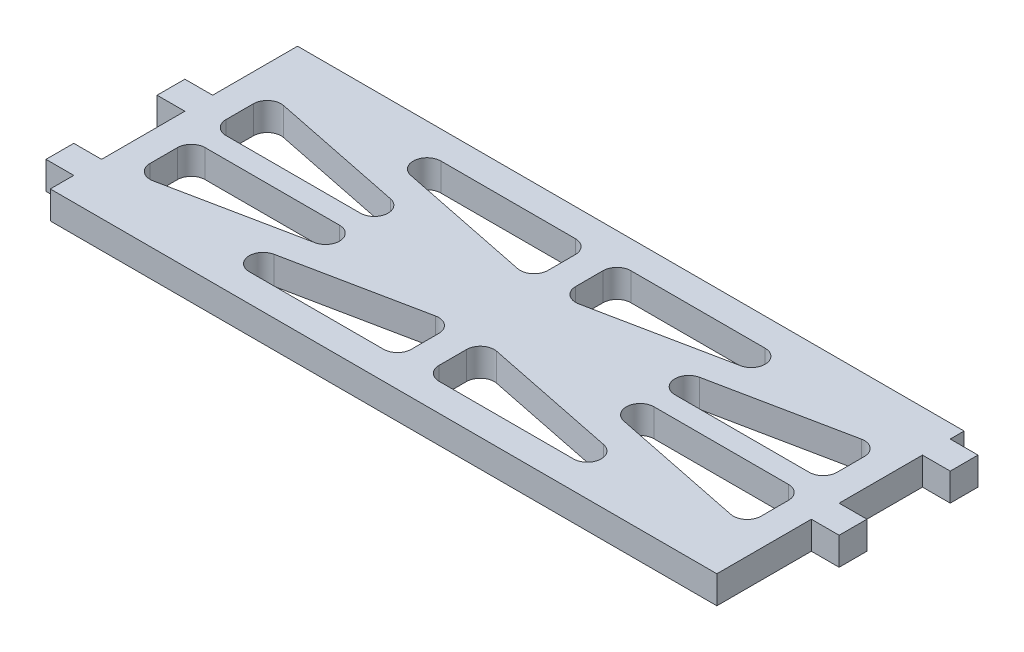
from build123d import *

# Parameters (mm, degrees)
BOSS_EXTRUDE1_DEPTH = 4
CUT_EXTRUDE1_DEPTH  = 10


with BuildPart() as part:
    # Sketch1 → Boss-Extrude1 (new body)
    with BuildSketch(Plane(origin=(0, 0, 0), x_dir=(1, 0, 0), z_dir=(0, 1, 0))):
        Polygon((-148, 18.23), (-148, 6), (-152, 6), (-152, 2), (-148, 2), (-148, -10), (-152, -10), (-152, -14), (-148, -14), (-148, -17.38), (-52, -17.38), (-52, -3.77), (-48, -3.77), (-48, 0.23), (-52, 0.23), (-52, 12.23), (-48, 12.23), (-48, 16.23), (-52, 16.23), (-52, 18.23), align=None)
    extrude(amount=-BOSS_EXTRUDE1_DEPTH)

    # Sketch2 → Cut-Extrude1 (cut)
    with BuildSketch(Plane(origin=(0, 0, 0), x_dir=(1, 0, 0), z_dir=(0, 1, 0))):
        with BuildLine():
            ThreePointArc((-144, 7.862318396), (-143.26536282, 9.411142768), (-141.601143065, 9.822143171))
            Line((-141.601143065, 9.822143171), (-122.254722174, 5.884824774))
            ThreePointArc((-122.254722174, 5.884824774), (-120.663648262, 3.724562414), (-122.653579109, 1.925))
            Line((-122.653579109, 1.925), (-142, 1.925))
            ThreePointArc((-142, 1.925), (-143.414213562, 2.510786438), (-144, 3.925))
            Line((-144, 3.925), (-144, 7.862318396))
        make_face()
        with BuildLine():
            Line((-123.346420891, 14.23), (-104, 14.23))
            ThreePointArc((-104, 14.23), (-102.585786438, 13.644213562), (-102, 12.23))
            Line((-102, 12.23), (-102, 8.292681604))
            ThreePointArc((-102, 8.292681604), (-102.73463718, 6.743857232), (-104.398856935, 6.332856829))
            Line((-104.398856935, 6.332856829), (-123.745277826, 10.270175226))
            ThreePointArc((-123.745277826, 10.270175226), (-125.336351738, 12.430437586), (-123.346420891, 14.23))
        make_face()
        with BuildLine():
            Line((-98, 12.23), (-98, 8.292681604))
            ThreePointArc((-98, 8.292681604), (-97.26536282, 6.743857232), (-95.601143065, 6.332856829))
            Line((-95.601143065, 6.332856829), (-76.254722174, 10.270175226))
            ThreePointArc((-76.254722174, 10.270175226), (-74.663648262, 12.430437586), (-76.653579109, 14.23))
            Line((-76.653579109, 14.23), (-96, 14.23))
            ThreePointArc((-96, 14.23), (-97.414213562, 13.644213562), (-98, 12.23))
        make_face()
        with BuildLine():
            ThreePointArc((-56, 3.925), (-56.585786438, 2.510786438), (-58, 1.925))
            Line((-58, 1.925), (-77.346420891, 1.925))
            ThreePointArc((-77.346420891, 1.925), (-79.336351738, 3.724562414), (-77.745277826, 5.884824774))
            Line((-77.745277826, 5.884824774), (-58.398856935, 9.822143171))
            ThreePointArc((-58.398856935, 9.822143171), (-56.73463718, 9.411142768), (-56, 7.862318396))
            Line((-56, 7.862318396), (-56, 3.925))
        make_face()
        with BuildLine():
            ThreePointArc((-56, -7.012318396), (-56.73463718, -8.561142768), (-58.398856935, -8.972143171))
            Line((-58.398856935, -8.972143171), (-77.745277826, -5.034824774))
            ThreePointArc((-77.745277826, -5.034824774), (-79.336351738, -2.874562414), (-77.346420891, -1.075))
            Line((-77.346420891, -1.075), (-58, -1.075))
            ThreePointArc((-58, -1.075), (-56.585786438, -1.660786438), (-56, -3.075))
            Line((-56, -3.075), (-56, -7.012318396))
        make_face()
        with BuildLine():
            Line((-76.653579109, -13.38), (-96, -13.38))
            ThreePointArc((-96, -13.38), (-97.414213562, -12.794213562), (-98, -11.38))
            Line((-98, -11.38), (-98, -7.442681604))
            ThreePointArc((-98, -7.442681604), (-97.26536282, -5.893857232), (-95.601143065, -5.482856829))
            Line((-95.601143065, -5.482856829), (-76.254722174, -9.420175226))
            ThreePointArc((-76.254722174, -9.420175226), (-74.663648262, -11.580437586), (-76.653579109, -13.38))
        make_face()
        with BuildLine():
            ThreePointArc((-144, -3.075), (-143.414213562, -1.660786438), (-142, -1.075))
            Line((-142, -1.075), (-122.653579109, -1.075))
            ThreePointArc((-122.653579109, -1.075), (-120.663648262, -2.874562414), (-122.254722174, -5.034824774))
            Line((-122.254722174, -5.034824774), (-141.601143065, -8.972143171))
            ThreePointArc((-141.601143065, -8.972143171), (-143.26536282, -8.561142768), (-144, -7.012318396))
            Line((-144, -7.012318396), (-144, -3.075))
        make_face()
        with BuildLine():
            Line((-104.398856935, -5.482856829), (-123.745277826, -9.420175226))
            ThreePointArc((-123.745277826, -9.420175226), (-125.336351738, -11.580437586), (-123.346420891, -13.38))
            Line((-123.346420891, -13.38), (-104, -13.38))
            ThreePointArc((-104, -13.38), (-102.585786438, -12.794213562), (-102, -11.38))
            Line((-102, -11.38), (-102, -7.442681604))
            ThreePointArc((-102, -7.442681604), (-102.73463718, -5.893857232), (-104.398856935, -5.482856829))
        make_face()
    extrude(amount=-CUT_EXTRUDE1_DEPTH, mode=Mode.SUBTRACT)


solid = part.part
